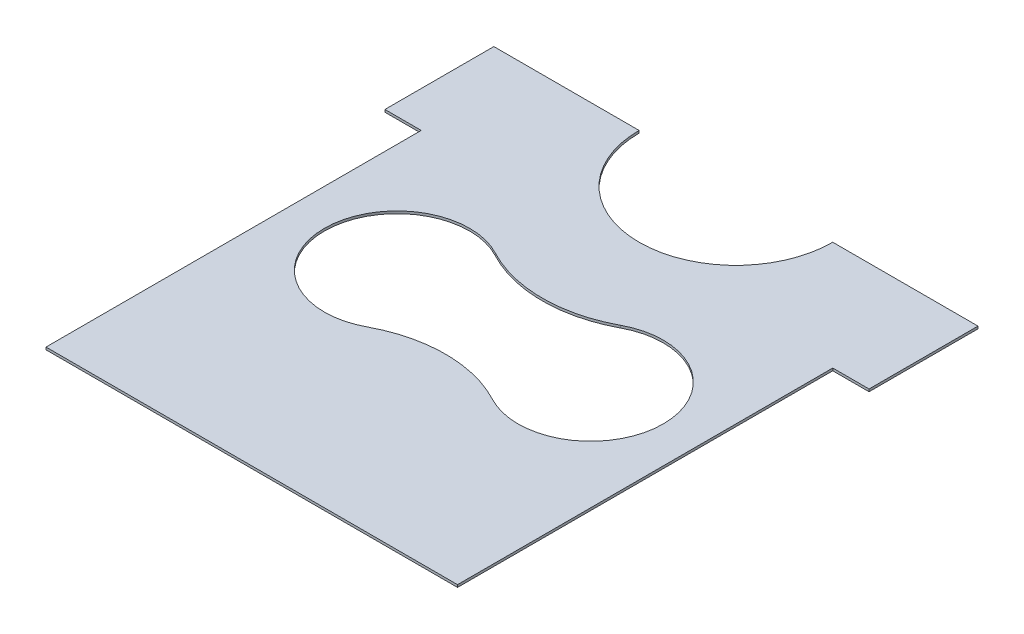
from build123d import *

# Parameters (mm, degrees)
EXTRUSION1_DEPTH = 10


with BuildPart() as part:
    # Esquisse1 → Extrusion1 (new body)
    with BuildSketch(Plane(origin=(0, 0, 0), x_dir=(1, 0, 0), z_dir=(0, 1, 0))):
        with BuildLine():
            Line((2350, 0), (650, 0))
            Line((650, 0), (650, 1550))
            Line((650, 1550), (500, 1550))
            Line((500, 1550), (500, 2000))
            Line((500, 2000), (1100, 2000))
            ThreePointArc((1100, 2000), (1500, 1600), (1900, 2000))
            Line((1900, 2000), (2500, 2000))
            Line((2500, 2000), (2500, 1550))
            Line((2500, 1550), (2350, 1550))
            Line((2350, 1550), (2350, 0))
        make_face()
        with BuildLine():
            ThreePointArc((1241.176470588, 1264.705882353), (800, 1000), (1241.176470588, 735.294117647))
            ThreePointArc((1241.176470588, 735.294117647), (1500, 800), (1758.823529412, 735.294117647))
            ThreePointArc((1758.823529412, 735.294117647), (2200, 1000), (1758.823529412, 1264.705882353))
            ThreePointArc((1758.823529412, 1264.705882353), (1500, 1200), (1241.176470588, 1264.705882353))
        make_face(mode=Mode.SUBTRACT)
    extrude(amount=EXTRUSION1_DEPTH)


solid = part.part
